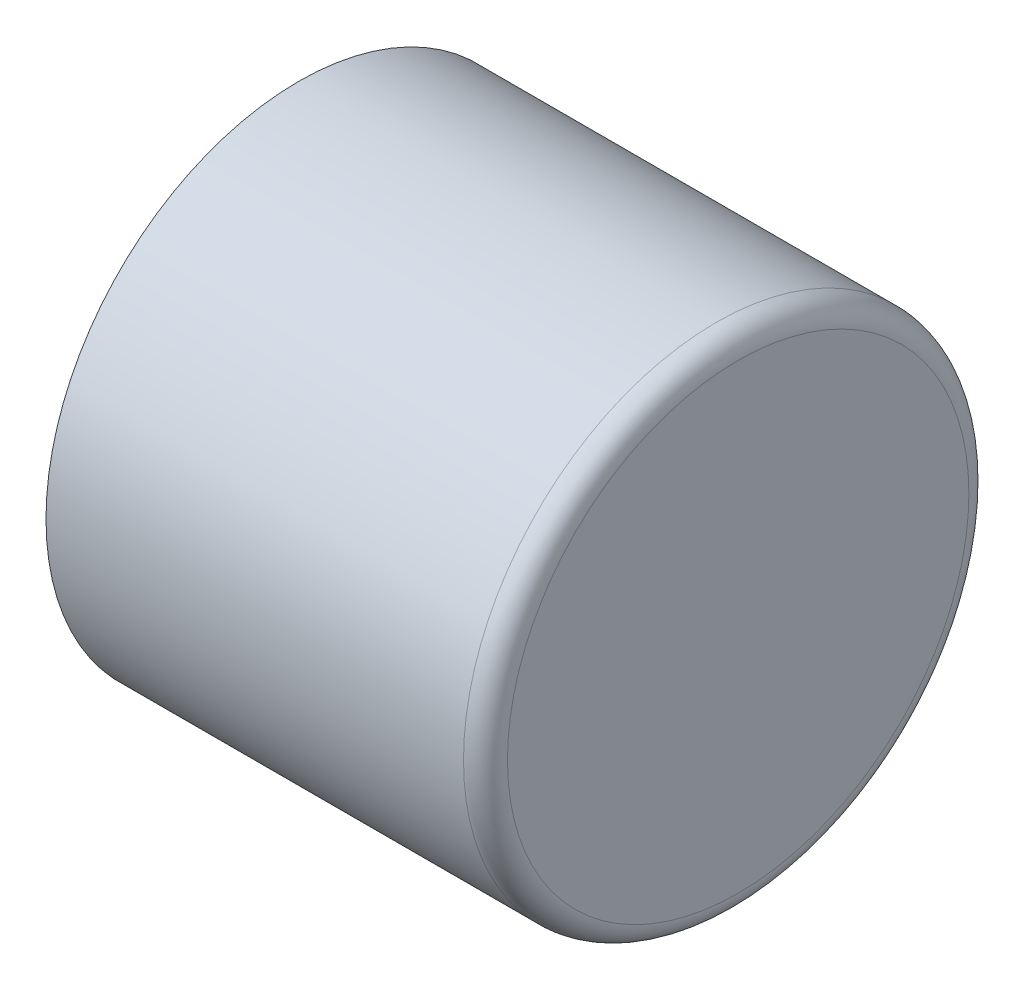
from build123d import *

# Parameters (mm, degrees)
SKETCH1_R           = 14.605
SKETCH1_R_2         = 12.7
BOSS_EXTRUDE1_DEPTH = 25.4
FILLET1_R           = 1.27
SKETCH3_R           = 12.7
BOSS_EXTRUDE2_DEPTH = 1.27


with BuildPart() as part:
    # Sketch1 → Boss-Extrude1 (new body)
    with BuildSketch(Plane(origin=(0, 0, 0), x_dir=(0, 0, -1), z_dir=(1, 0, 0))):
        Circle(SKETCH1_R)
        Circle(SKETCH1_R_2, mode=Mode.SUBTRACT)
    extrude(amount=BOSS_EXTRUDE1_DEPTH)

    # Fillet1
    fillet1_edges = [part.edges().sort_by_distance(p)[0] for p in [
        (25.4, 0, 14.605),
    ]]
    fillet(fillet1_edges, radius=FILLET1_R)

    # Sketch3 → Boss-Extrude2 (add)
    with BuildSketch(Plane(origin=(25.4, 0, 0), x_dir=(0, 0, -1), z_dir=(1, 0, 0))):
        Circle(SKETCH3_R)
    extrude(amount=-BOSS_EXTRUDE2_DEPTH)


solid = part.part
